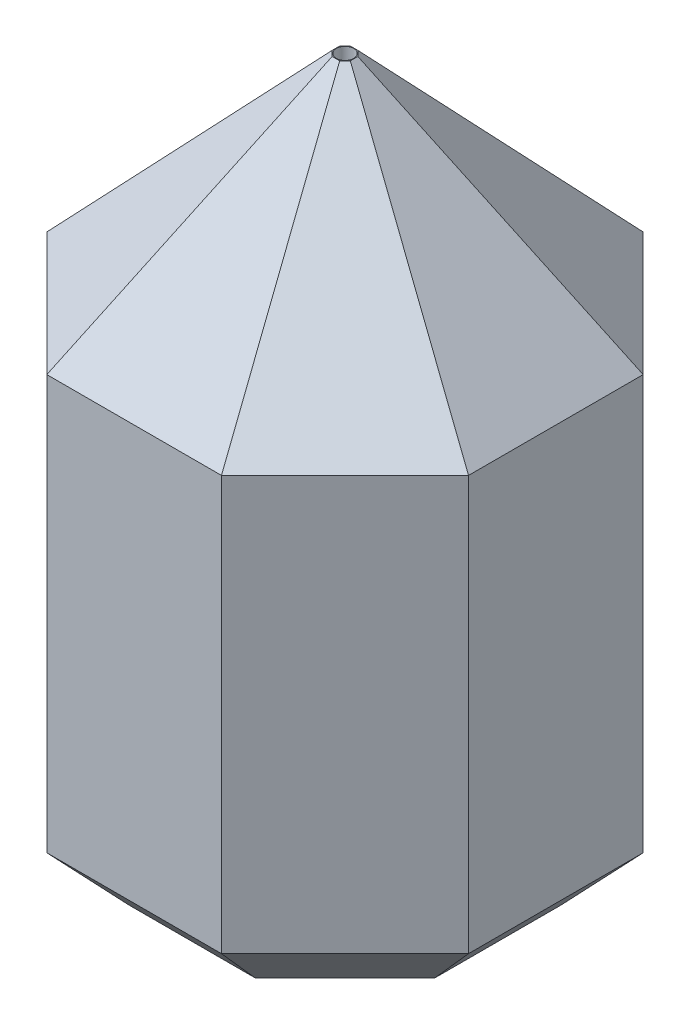
from build123d import *
from OCP.BRepFilletAPI import BRepFilletAPI_MakeChamfer

# Parameters (mm, degrees)
SKETCH1_W           = 34
SKETCH1_H           = 34
BOSS_EXTRUDE1_DEPTH = 120
SKETCH2_W           = 34
SKETCH2_H           = 34
SKETCH2_R           = 1.5
BOSS_EXTRUDE2_DEPTH = 20
SKETCH4_W           = 34
SKETCH4_H           = 34
SKETCH4_R           = 1.5
BOSS_EXTRUDE5_DEPTH = 15
SKETCH3_W           = 34
SKETCH3_H           = 34
SKETCH3_R           = 8
BOSS_EXTRUDE3_DEPTH = 13
CHAMFER1_SIZE       = 37.5
CHAMFER1_SIZE2      = 34.96931573
CHAMFER2_SIZE       = 10
CHAMFER2_SIZE2      = 10.7236871
SKETCH5_W           = 5
SKETCH5_H           = 4
CUT_EXTRUDE1_DEPTH  = 20


with BuildPart() as part:
    # Sketch1 → Boss-Extrude1 (new body)
    with BuildSketch(Plane(origin=(0, 0, 0), x_dir=(1, 0, 0), z_dir=(0, 1, 0))):
        Polygon((-15.136038969, 36.54163056), (-36.54163056, 15.136038969), (-36.54163056, -15.136038969), (-15.136038969, -36.54163056), (15.136038969, -36.54163056), (36.54163056, -15.136038969), (36.54163056, 15.136038969), (15.136038969, 36.54163056), align=None)
        Rectangle(SKETCH1_W, SKETCH1_H, mode=Mode.SUBTRACT)
    extrude(amount=BOSS_EXTRUDE1_DEPTH)

    # Sketch2 → Boss-Extrude2 (add)
    with BuildSketch(Plane(origin=(0, 120, 0), x_dir=(1, 0, 0), z_dir=(0, 1, 0))):
        Polygon((36.54163056, 15.136038969), (15.136038969, 36.54163056), (-15.136038969, 36.54163056), (-36.54163056, 15.136038969), (-36.54163056, -15.136038969), (-15.136038969, -36.54163056), (15.136038969, -36.54163056), (36.54163056, -15.136038969), align=None)
        Rectangle(SKETCH2_W, SKETCH2_H, mode=Mode.SUBTRACT)
        Rectangle(SKETCH2_W, SKETCH2_H)
        with Locations(Location((0, 0, 0), (0, 0, 270))):
            Circle(SKETCH2_R, mode=Mode.SUBTRACT)
    extrude(amount=-BOSS_EXTRUDE2_DEPTH)

    # Sketch4 → Boss-Extrude5 (add)
    with BuildSketch(Plane.XZ.offset(-100)):
        Rectangle(SKETCH4_W, SKETCH4_H)
        with Locations(Location((0, 0, 0), (0, 0, 90))):
            Circle(SKETCH4_R, mode=Mode.SUBTRACT)
    extrude(amount=BOSS_EXTRUDE5_DEPTH)

    # Sketch3 → Boss-Extrude3 (add)
    with BuildSketch(Plane.XZ.offset(-85)):
        Rectangle(SKETCH3_W, SKETCH3_H)
        with Locations(Location((0, 0, 0), (0, 0, 90))):
            Circle(SKETCH3_R, mode=Mode.SUBTRACT)
    extrude(amount=BOSS_EXTRUDE3_DEPTH)

    # Chamfer1: one chamfer whose edges measure the first distance from different faces: ONE call of the kernel's chamfer builder (chamfer() names one face for all edges)
    chamfer1_edges_1 = [part.edges().sort_by_distance(p)[0] for p in [
        (-36.54163056, 120, 0),
    ]]
    chamfer1_side_1 = [part.faces().sort_by_distance(p)[0] for p in [
        (-36.54163056, 60, 0),
    ]]
    chamfer1_edges_2 = [part.edges().sort_by_distance(p)[0] for p in [
        (-25.838834765, 120, 25.838834765),
    ]]
    chamfer1_side_2 = [part.faces().sort_by_distance(p)[0] for p in [
        (-25.838834765, 60, 25.838834765),
    ]]
    chamfer1_edges_3 = [part.edges().sort_by_distance(p)[0] for p in [
        (0, 120, 36.54163056),
    ]]
    chamfer1_side_3 = [part.faces().sort_by_distance(p)[0] for p in [
        (0, 60, 36.54163056),
    ]]
    chamfer1_edges_4 = [part.edges().sort_by_distance(p)[0] for p in [
        (25.838834765, 120, 25.838834765),
    ]]
    chamfer1_side_4 = [part.faces().sort_by_distance(p)[0] for p in [
        (25.838834765, 60, 25.838834765),
    ]]
    chamfer1_edges_5 = [part.edges().sort_by_distance(p)[0] for p in [
        (36.54163056, 120, 0),
    ]]
    chamfer1_side_5 = [part.faces().sort_by_distance(p)[0] for p in [
        (36.54163056, 60, 0),
    ]]
    chamfer1_edges_6 = [part.edges().sort_by_distance(p)[0] for p in [
        (25.838834765, 120, -25.838834765),
    ]]
    chamfer1_side_6 = [part.faces().sort_by_distance(p)[0] for p in [
        (25.838834765, 60, -25.838834765),
    ]]
    chamfer1_edges_7 = [part.edges().sort_by_distance(p)[0] for p in [
        (0, 120, -36.54163056),
    ]]
    chamfer1_side_7 = [part.faces().sort_by_distance(p)[0] for p in [
        (0, 60, -36.54163056),
    ]]
    chamfer1_edges_8 = [part.edges().sort_by_distance(p)[0] for p in [
        (-25.838834765, 120, -25.838834765),
    ]]
    chamfer1_side_8 = [part.faces().sort_by_distance(p)[0] for p in [
        (-25.838834765, 60, -25.838834765),
    ]]
    chamfer1 = BRepFilletAPI_MakeChamfer(part.part.solid().wrapped)
    for e in chamfer1_edges_1:
        chamfer1.Add(CHAMFER1_SIZE, CHAMFER1_SIZE2, e.wrapped, chamfer1_side_1[0].wrapped)  # the first distance lies on this face
    for e in chamfer1_edges_2:
        chamfer1.Add(CHAMFER1_SIZE, CHAMFER1_SIZE2, e.wrapped, chamfer1_side_2[0].wrapped)  # the first distance lies on this face
    for e in chamfer1_edges_3:
        chamfer1.Add(CHAMFER1_SIZE, CHAMFER1_SIZE2, e.wrapped, chamfer1_side_3[0].wrapped)  # the first distance lies on this face
    for e in chamfer1_edges_4:
        chamfer1.Add(CHAMFER1_SIZE, CHAMFER1_SIZE2, e.wrapped, chamfer1_side_4[0].wrapped)  # the first distance lies on this face
    for e in chamfer1_edges_5:
        chamfer1.Add(CHAMFER1_SIZE, CHAMFER1_SIZE2, e.wrapped, chamfer1_side_5[0].wrapped)  # the first distance lies on this face
    for e in chamfer1_edges_6:
        chamfer1.Add(CHAMFER1_SIZE, CHAMFER1_SIZE2, e.wrapped, chamfer1_side_6[0].wrapped)  # the first distance lies on this face
    for e in chamfer1_edges_7:
        chamfer1.Add(CHAMFER1_SIZE, CHAMFER1_SIZE2, e.wrapped, chamfer1_side_7[0].wrapped)  # the first distance lies on this face
    for e in chamfer1_edges_8:
        chamfer1.Add(CHAMFER1_SIZE, CHAMFER1_SIZE2, e.wrapped, chamfer1_side_8[0].wrapped)  # the first distance lies on this face
    add(Compound.cast(chamfer1.Shape()), mode=Mode.REPLACE)

    # Chamfer2
    chamfer2_edges = [part.edges().sort_by_distance(p)[0] for p in [
        (-25.838834765, 0, -25.838834765),
        (0, 0, -36.54163056),
        (25.838834765, 0, -25.838834765),
        (36.54163056, 0, 0),
        (25.838834765, 0, 25.838834765),
        (0, 0, 36.54163056),
        (-25.838834765, 0, 25.838834765),
        (-36.54163056, 0, 0),
    ]]
    chamfer2_side = [part.faces().sort_by_distance(p)[0] for p in [
        (-25.108002154, 0, -25.108002154),
    ]]
    chamfer(chamfer2_edges, length=CHAMFER2_SIZE, length2=CHAMFER2_SIZE2, reference=chamfer2_side[0])

    # Sketch5 → Cut-Extrude1 (cut)
    with BuildSketch(Plane.XZ):
        with Locations((-19.5, 0)):
            Rectangle(SKETCH5_W, SKETCH5_H)
    extrude(amount=-CUT_EXTRUDE1_DEPTH, mode=Mode.SUBTRACT)


solid = part.part
